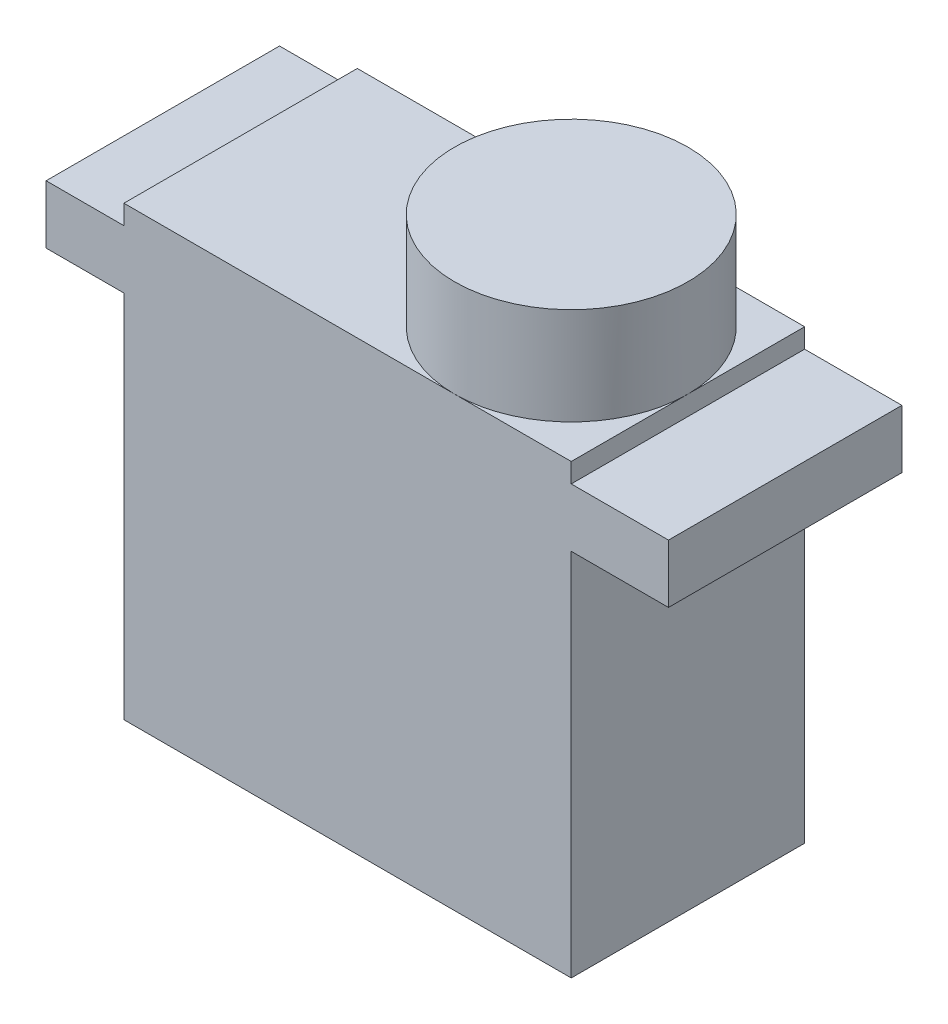
from build123d import *

# Parameters (mm, degrees)
CORPS_SERVO_W      = 23
CORPS_SERVO_H      = 12
BOSS_EXTRU_2_DEPTH = 19
PLAQUE_TROUS_W     = 32
PLAQUE_TROUS_H     = 12
BOSS_EXTRU_3_DEPTH = 3
ESQUISSE5_W        = 23
ESQUISSE5_H        = 12
BOSS_EXTRU_4_DEPTH = 1
ESQUISSE6_R        = 6
BOSS_EXTRU_5_DEPTH = 5


with BuildPart() as part:
    # corps servo → Boss.-Extru.2 (new body)
    with BuildSketch(Plane(origin=(0, 0, 0), x_dir=(1, 0, 0), z_dir=(0, 1, 0))):
        with Locations((11.5, 6)):
            Rectangle(CORPS_SERVO_W, CORPS_SERVO_H)
    extrude(amount=BOSS_EXTRU_2_DEPTH)

    # plaque trous → Boss.-Extru.3 (add)
    with BuildSketch(Plane(origin=(0, 19, 0), x_dir=(1, 0, 0), z_dir=(0, 1, 0))):
        with Locations((12, 6)):
            Rectangle(PLAQUE_TROUS_W, PLAQUE_TROUS_H)
    extrude(amount=BOSS_EXTRU_3_DEPTH)

    # Esquisse5 → Boss.-Extru.4 (add)
    with BuildSketch(Plane(origin=(0, 22, 0), x_dir=(1, 0, 0), z_dir=(0, 1, 0))):
        with Locations((11.5, 6)):
            Rectangle(ESQUISSE5_W, ESQUISSE5_H)
    extrude(amount=BOSS_EXTRU_4_DEPTH)

    # Esquisse6 → Boss.-Extru.5 (add)
    with BuildSketch(Plane(origin=(0, 23, 0), x_dir=(1, 0, 0), z_dir=(0, 1, 0))):
        with Locations((17, 6)):
            Circle(ESQUISSE6_R)
    extrude(amount=BOSS_EXTRU_5_DEPTH)


solid = part.part
